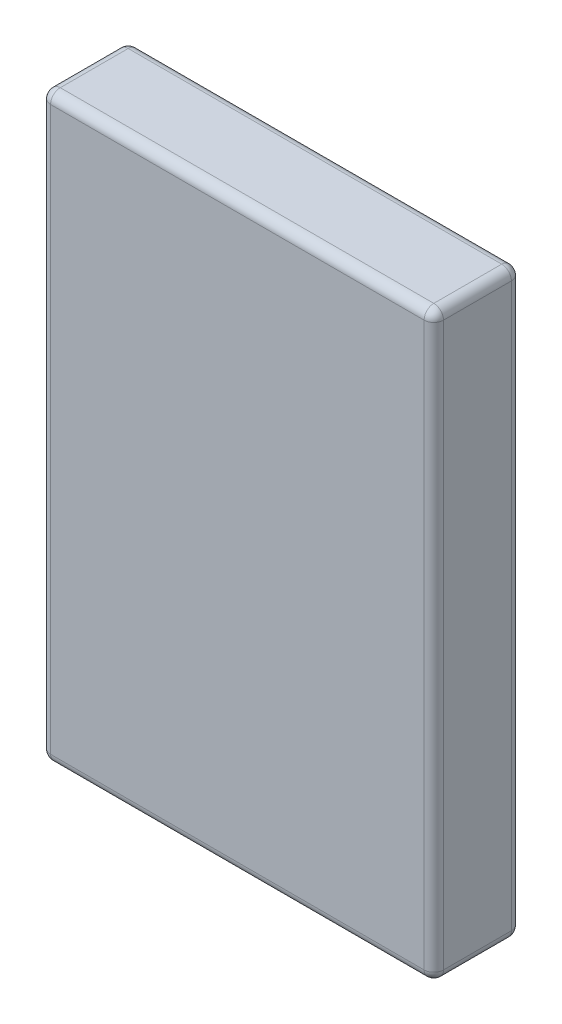
from build123d import *

# Parameters (mm, degrees)
SKETCH2_W           = 162
SKETCH2_H           = 36
BOSS_EXTRUDE1_DEPTH = 240
FILLET1_R           = 4


with BuildPart() as part:
    # Sketch2 → Boss-Extrude1 (new body)
    with BuildSketch(Plane(origin=(0, 0, 0), x_dir=(1, 0, 0), z_dir=(0, 1, 0))):
        Rectangle(SKETCH2_W, SKETCH2_H)
    extrude(amount=BOSS_EXTRUDE1_DEPTH)

    # Fillet1
    fillet1_edges = [part.edges().sort_by_distance(p)[0] for p in [
        (-81, 240, 0),
        (0, 240, 18),
        (81, 240, 0),
        (0, 0, 18),
        (-81, 0, 0),
        (0, 0, -18),
        (81, 0, 0),
        (81, 120, 18),
        (-81, 120, 18),
        (-81, 120, -18),
        (81, 120, -18),
        (0, 240, -18),
    ]]
    fillet(fillet1_edges, radius=FILLET1_R)


solid = part.part
